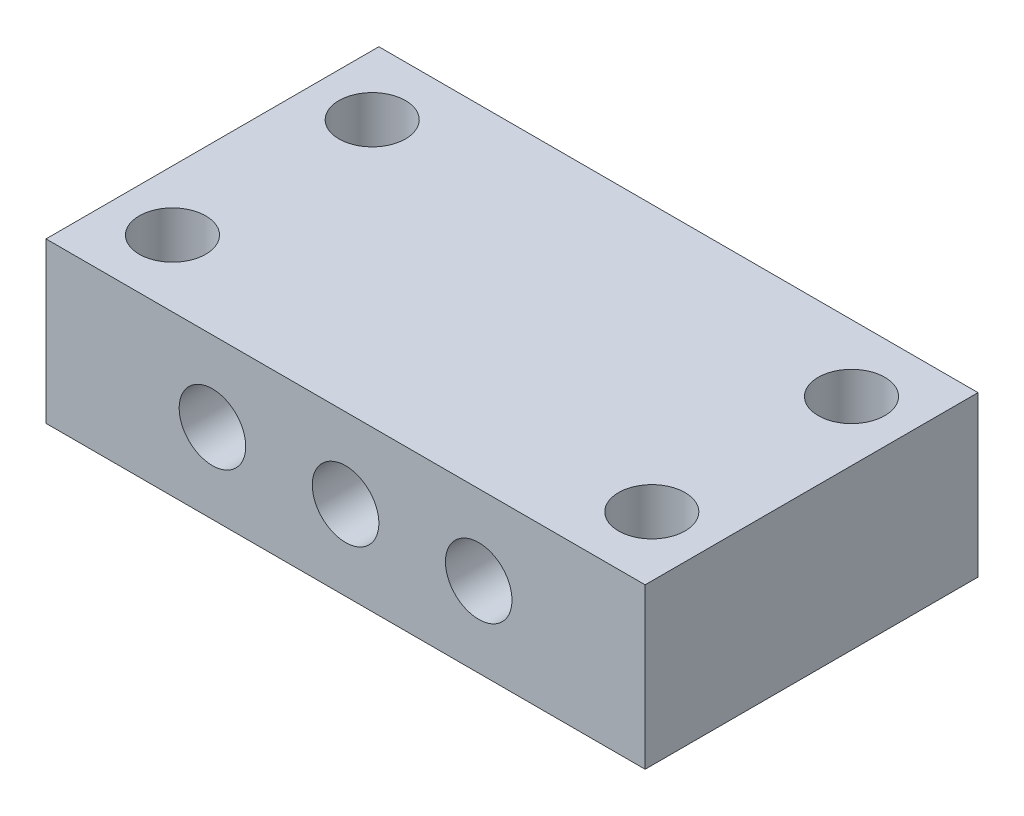
from build123d import *

# Parameters (mm, degrees)
SKETCH1_W           = 45
SKETCH1_H           = 25
BOSS_EXTRUDE1_DEPTH = 12
SKETCH2_R           = 2.5
CUT_EXTRUDE1_DEPTH  = 12
SKETCH3_R           = 2.5
CUT_EXTRUDE2_DEPTH  = 72
SKETCH4_R           = 2.5
CUT_EXTRUDE3_DEPTH  = 72


with BuildPart() as part:
    # Sketch1 → Boss-Extrude1 (new body)
    with BuildSketch(Plane(origin=(0, 0, 0), x_dir=(1, 0, 0), z_dir=(0, 1, 0))):
        Rectangle(SKETCH1_W, SKETCH1_H)
    extrude(amount=BOSS_EXTRUDE1_DEPTH)

    # Sketch2 → Cut-Extrude1 (cut)
    with BuildSketch(Plane(origin=(0, 12, 0), x_dir=(1, 0, 0), z_dir=(0, 1, 0))):
        with Locations((-18, -7.5)):
            Circle(SKETCH2_R)
        with Locations((-18, 7.5)):
            Circle(SKETCH2_R)
        with Locations((18, -7.5)):
            Circle(SKETCH2_R)
        with Locations((18, 7.5)):
            Circle(SKETCH2_R)
    extrude(amount=-CUT_EXTRUDE1_DEPTH, mode=Mode.SUBTRACT)

    # Sketch3 → Cut-Extrude2 (cut)
    with BuildSketch(Plane(origin=(0, 0, -12.5), x_dir=(-1, 0, 0), z_dir=(0, 0, -1))):
        with Locations((0, 6)):
            Circle(SKETCH3_R)
    extrude(amount=-CUT_EXTRUDE2_DEPTH, mode=Mode.SUBTRACT)

    # Sketch4 → Cut-Extrude3 (cut)
    with BuildSketch(Plane(origin=(0, 0, -12.5), x_dir=(-1, 0, 0), z_dir=(0, 0, -1))):
        with Locations((10, 6)):
            Circle(SKETCH4_R)
        with Locations((-10, 6)):
            Circle(SKETCH4_R)
    extrude(amount=-CUT_EXTRUDE3_DEPTH, mode=Mode.SUBTRACT)


solid = part.part
